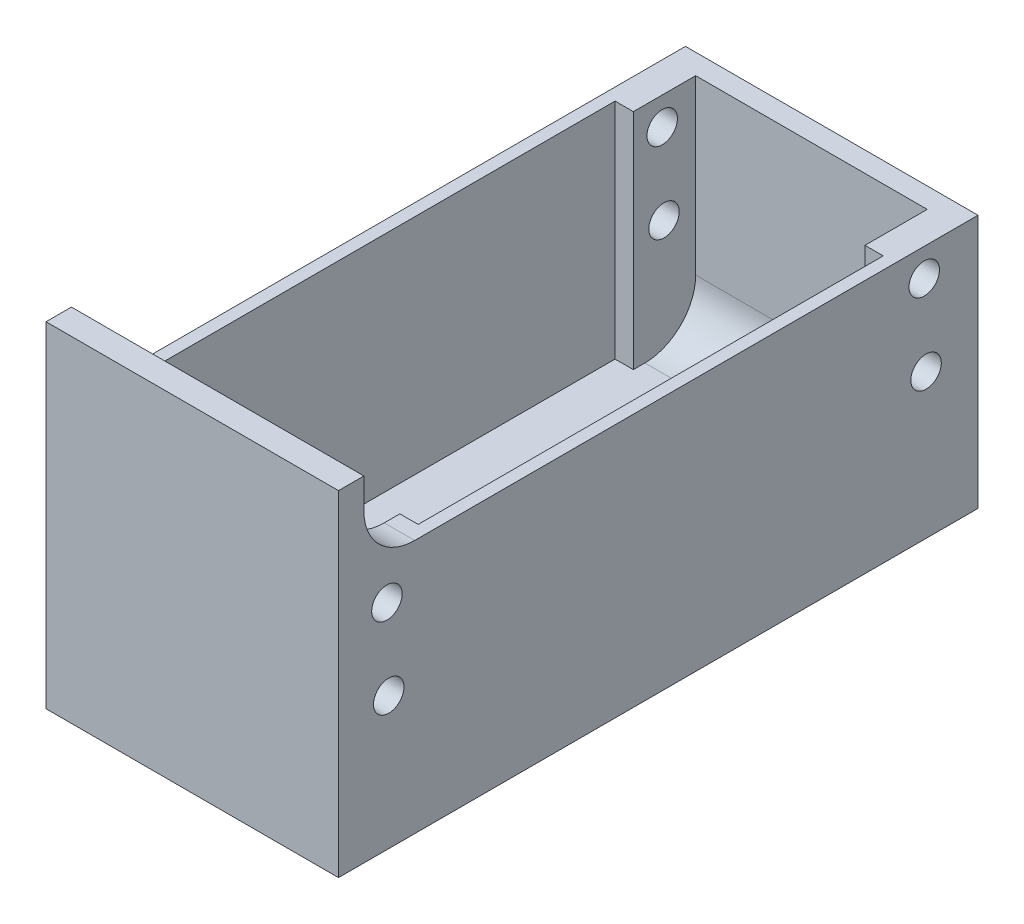
from build123d import *

# Parameters (mm, degrees)
EXTRUDE_1_DEPTH     = 62.96
SKETCH_2_W          = 28.8
SKETCH_2_H          = 2
EXTRUDE_2_DEPTH     = 22
SKETCH_7_W          = 1.8
SKETCH_7_H          = 45.791930202
CUT_EXTRUDE_1_DEPTH = 22
FILLET_2_R          = 5
MM_PRESS_3_D        = 3
SKETCH_14_W         = 28.8
SKETCH_14_H         = 2.5
EXTRUDE_3_DEPTH     = 30
FILLET_3_R          = 6
FILLET_4_R          = 5


with BuildPart() as part:
    # 草图1 → 凸台-拉伸1 (new body)
    with BuildSketch(Plane.XY):
        Polygon((-13.750151713, 26.893062898), (-13.750151713, 1.893062898), (15.049848287, 1.893062898), (15.049848287, 26.893062898), (12.049848287, 26.893062898), (12.049848287, 4.893062898), (-10.750151713, 4.893062898), (-10.750151713, 26.893062898), align=None)
    extrude(amount=EXTRUDE_1_DEPTH)

    # 草图2 → 凸台-拉伸2 (add)
    with BuildSketch(Plane(origin=(0, 4.893062898, 0), x_dir=(1, 0, 0), z_dir=(0, 1, 0))):
        with Locations((0.649848287, -1)):
            Rectangle(SKETCH_2_W, SKETCH_2_H)
    extrude(amount=EXTRUDE_2_DEPTH)

    # 草图7 → 切除-拉伸1 (cut)
    with BuildSketch(Plane(origin=(0, 4.893062898, 0), x_dir=(1, 0, 0), z_dir=(0, 1, 0))):
        with Locations((-11.650151713, -31.026293471)):
            Rectangle(SKETCH_7_W, SKETCH_7_H)
        with Locations((12.949848287, -31.026293471)):
            Rectangle(SKETCH_7_W, SKETCH_7_H)
    extrude(amount=CUT_EXTRUDE_1_DEPTH, mode=Mode.SUBTRACT)

    # 圆角2
    fillet_2_edges = [part.edges().sort_by_distance(p)[0] for p in [
        (0.649848287, 4.893062898, 2),
    ]]
    fillet(fillet_2_edges, radius=FILLET_2_R)

    # 大小mm Press 暗销孔3 (through all)
    with Locations(Plane(origin=(15.049848287, 207.544632648, -30.881320252), x_dir=(0, -0.022253058, 0.99975237), z_dir=(1, 0, 0))):
        with Locations((93.161367469, 190.578219389), (93.161367469, 182.547127137), (40.245392963, 190.578219389), (40.245392963, 182.547127137)):
            Hole(MM_PRESS_3_D / 2)

    # 草图14 → 凸台-拉伸3 (add)
    with BuildSketch(Plane(origin=(0, 4.893062898, 0), x_dir=(1, 0, 0), z_dir=(0, 1, 0))):
        with Locations((0.649848287, -61.71)):
            Rectangle(SKETCH_14_W, SKETCH_14_H)
    extrude(amount=EXTRUDE_3_DEPTH)

    # 圆角3
    fillet_3_edges = [part.edges().sort_by_distance(p)[0] for p in [
        (0.649848287, 4.893062898, 60.46),
    ]]
    fillet(fillet_3_edges, radius=FILLET_3_R)

    # 圆角4
    fillet_4_edges = [part.edges().sort_by_distance(p)[0] for p in [
        (13.549848287, 26.893062898, 60.46),
        (-12.250151713, 26.893062898, 60.46),
    ]]
    fillet(fillet_4_edges, radius=FILLET_4_R)


solid = part.part
